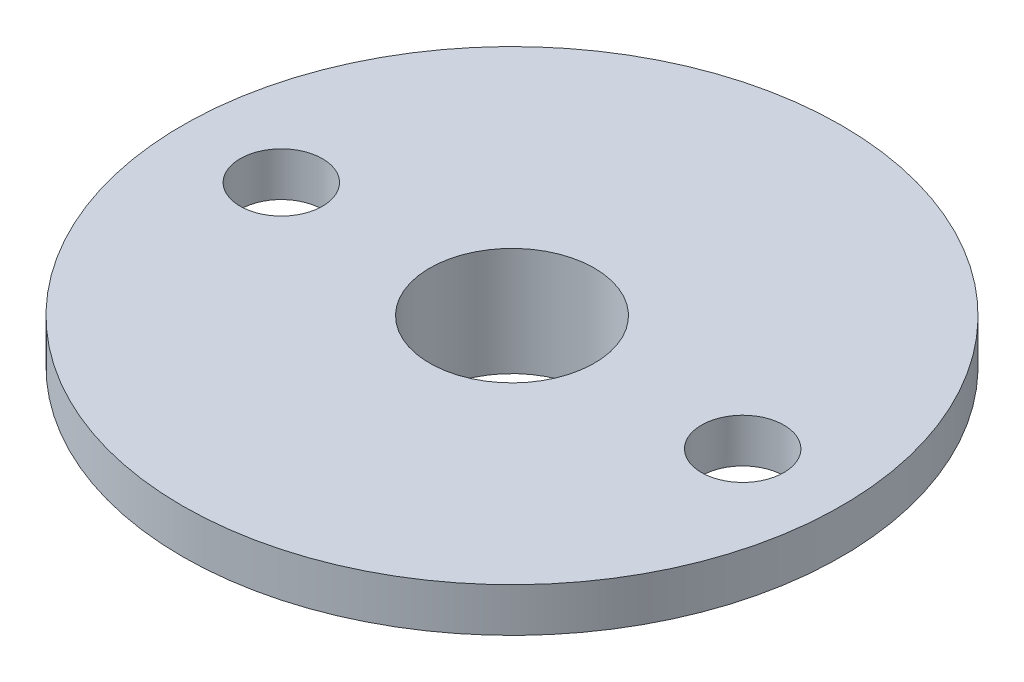
from build123d import *

# Parameters (mm, degrees)
SKETCH2_R          = 1.5
CUT_EXTRUDE1_DEPTH = 4.95


with BuildPart() as part:
    # Sketch1 → Revolve1 (revolve)
    with BuildSketch(Plane.XY):
        Polygon((12, 0), (12, -1.6), (5, -1.6), (5, -3.95), (3, -3.95), (3, 0), align=None)
    revolve(axis=Axis((0, 0, 0), (0, 1, 0)))

    # Sketch2 → Cut-Extrude1 (cut, through all)
    with BuildSketch(Plane(origin=(0, 0, 0), x_dir=(1, 0, 0), z_dir=(0, 1, 0))):
        with Locations((8.4, 0)):
            Circle(SKETCH2_R)
        with Locations((-8.4, 0)):
            Circle(SKETCH2_R)
    extrude(amount=-CUT_EXTRUDE1_DEPTH, mode=Mode.SUBTRACT)


solid = part.part
